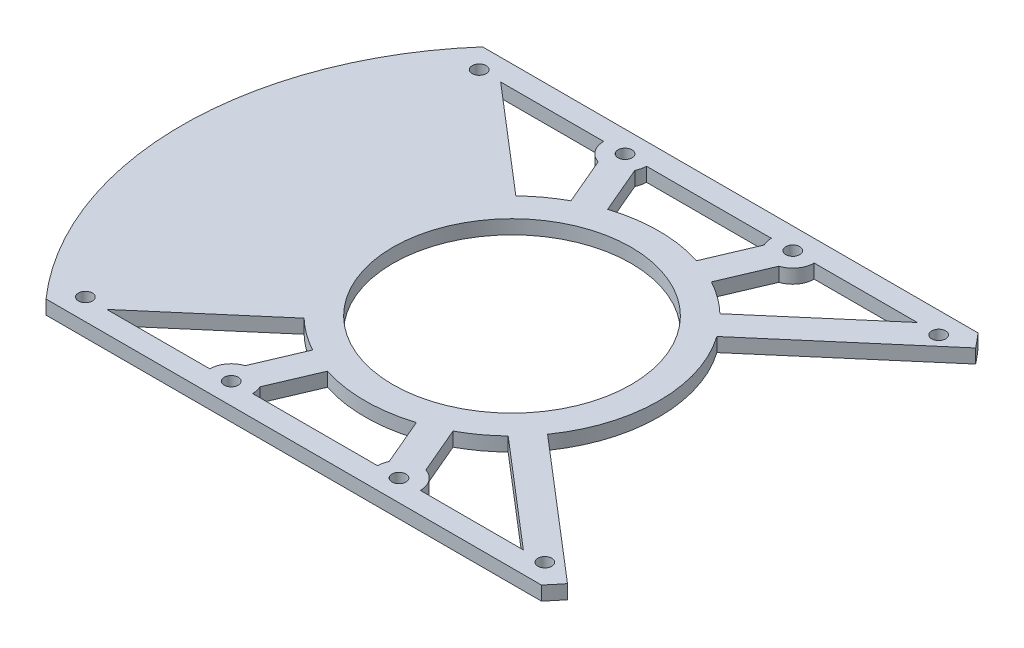
from build123d import *

# Parameters (mm, degrees)
SKETCH1_R           = 75
BOSS_EXTRUDE1_DEPTH = 3.175
CUT_EXTRUDE1_DEPTH  = 3.175
SKETCH3_R           = 1.5875
CUT_EXTRUDE2_DEPTH  = 3.175
SKETCH4_R           = 27.051
CUT_EXTRUDE3_DEPTH  = 3.175
CUT_EXTRUDE4_DEPTH  = 3.175


with BuildPart() as part:
    # Sketch1 → Boss-Extrude1 (new body)
    with BuildSketch(Plane(origin=(0, 0, 0), x_dir=(1, 0, 0), z_dir=(0, 1, 0))):
        Circle(SKETCH1_R)
    extrude(amount=BOSS_EXTRUDE1_DEPTH)

    # Sketch2 → Cut-Extrude1 (cut)
    with BuildSketch(Plane(origin=(0, 3.175, 0), x_dir=(1, 0, 0), z_dir=(0, 1, 0))):
        with BuildLine():
            Line((-56.262005909, -49.594220339), (56.262005909, -49.594220339))
            ThreePointArc((56.262005909, -49.594220339), (0, -75), (-56.262005909, -49.594220339))
        make_face()
        with BuildLine():
            Line((-56.262005909, 49.594220339), (56.262005909, 49.594220339))
            ThreePointArc((56.262005909, 49.594220339), (0, 75), (-56.262005909, 49.594220339))
        make_face()
    extrude(amount=-CUT_EXTRUDE1_DEPTH, mode=Mode.SUBTRACT)

    # Sketch3 → Cut-Extrude2 (cut)
    with BuildSketch(Plane(origin=(0, 3.175, 0), x_dir=(1, 0, 0), z_dir=(0, 1, 0))):
        with Locations((-52.180304588, 44.729838125)):
            Circle(SKETCH3_R)
        with Locations((-19.05, 44.729838125)):
            Circle(SKETCH3_R)
        with Locations((19.05, 44.729838125)):
            Circle(SKETCH3_R)
        with Locations((52.180304588, 44.729838125)):
            Circle(SKETCH3_R)
        with Locations((52.180304588, -44.729838125)):
            Circle(SKETCH3_R)
        with Locations((19.05, -44.729838125)):
            Circle(SKETCH3_R)
        with Locations((-19.05, -44.729838125)):
            Circle(SKETCH3_R)
        with Locations((-52.180304588, -44.729838125)):
            Circle(SKETCH3_R)
    extrude(amount=-CUT_EXTRUDE2_DEPTH, mode=Mode.SUBTRACT)

    # Sketch4 → Cut-Extrude3 (cut)
    with BuildSketch(Plane(origin=(0, 3.175, 0), x_dir=(1, 0, 0), z_dir=(0, 1, 0))):
        with BuildLine():
            Line((-47.315937317, 44.741895283), (-23.177806764, 24.050282215))
            ThreePointArc((-23.177806764, 24.050282215), (-19.742091457, 26.942097653), (-15.949506316, 29.346891646))
            Line((-15.949506316, 29.346891646), (-20.527078848, 40.095137229))
            ThreePointArc((-20.527078848, 40.095137229), (-22.980849122, 41.864416778), (-23.914367271, 44.741895283))
            Line((-23.914367271, 44.741895283), (-47.315937317, 44.741895283))
        make_face()
        with BuildLine():
            ThreePointArc((10.107278818, 31.835039122), (0, 33.401), (-10.107278818, 31.835039122))
            Line((-10.107278818, 31.835039122), (-14.68485135, 42.583284705))
            ThreePointArc((-14.68485135, 42.583284705), (-14.312069768, 43.627916425), (-14.185617786, 44.729838125))
            Line((-14.185617786, 44.729838125), (14.185617786, 44.729838125))
            ThreePointArc((14.185617786, 44.729838125), (14.312069768, 43.627916425), (14.68485135, 42.583284705))
            Line((14.68485135, 42.583284705), (10.107278818, 31.835039122))
        make_face()
        with BuildLine():
            ThreePointArc((15.949506316, 29.346891646), (19.742091457, 26.942097653), (23.177806764, 24.050282215))
            Line((23.177806764, 24.050282215), (47.315937317, 44.741895283))
            Line((47.315937317, 44.741895283), (23.914382214, 44.729838125))
            ThreePointArc((23.914382214, 44.729838125), (22.977294896, 41.859547352), (20.527078848, 40.095137229))
            Line((20.527078848, 40.095137229), (15.949506316, 29.346891646))
        make_face()
        Circle(SKETCH4_R)
        with BuildLine():
            Line((-23.177806764, -24.050282215), (-47.315937317, -44.741895283))
            Line((-47.315937317, -44.741895283), (-23.914382214, -44.729838125))
            ThreePointArc((-23.914382214, -44.729838125), (-22.977294896, -41.859547352), (-20.527078848, -40.095137229))
            Line((-20.527078848, -40.095137229), (-15.949506316, -29.346891646))
            ThreePointArc((-15.949506316, -29.346891646), (-19.742091457, -26.942097653), (-23.177806764, -24.050282215))
        make_face()
        with BuildLine():
            ThreePointArc((-10.107278818, -31.835039122), (0, -33.401), (10.107278818, -31.835039122))
            Line((10.107278818, -31.835039122), (14.68485135, -42.583284705))
            ThreePointArc((14.68485135, -42.583284705), (14.312069768, -43.627916425), (14.185617786, -44.729838125))
            Line((14.185617786, -44.729838125), (-14.185617786, -44.729838125))
            ThreePointArc((-14.185617786, -44.729838125), (-14.312069768, -43.627916425), (-14.68485135, -42.583284705))
            Line((-14.68485135, -42.583284705), (-10.107278818, -31.835039122))
        make_face()
        with BuildLine():
            ThreePointArc((23.177806764, -24.050282215), (19.742091457, -26.942097653), (15.949506316, -29.346891646))
            Line((15.949506316, -29.346891646), (20.527078848, -40.095137229))
            ThreePointArc((20.527078848, -40.095137229), (22.977294896, -41.859547352), (23.914382214, -44.729838125))
            Line((23.914382214, -44.729838125), (47.315937317, -44.741895283))
            Line((47.315937317, -44.741895283), (23.177806764, -24.050282215))
        make_face()
    extrude(amount=-CUT_EXTRUDE3_DEPTH, mode=Mode.SUBTRACT)

    # Sketch5 → Cut-Extrude4 (cut)
    with BuildSketch(Plane(origin=(0, 3.175, 0), x_dir=(1, 0, 0), z_dir=(0, 1, 0))):
        with BuildLine():
            Line((58.957481542, 46.357473725), (27.31053772, 19.229179141))
            ThreePointArc((27.31053772, 19.229179141), (33.401, 0), (27.31053772, -19.229179141))
            Line((27.31053772, -19.229179141), (58.957481542, -46.357473725))
            ThreePointArc((58.957481542, -46.357473725), (75, 0), (58.957481542, 46.357473725))
        make_face()
    extrude(amount=-CUT_EXTRUDE4_DEPTH, mode=Mode.SUBTRACT)


solid = part.part
